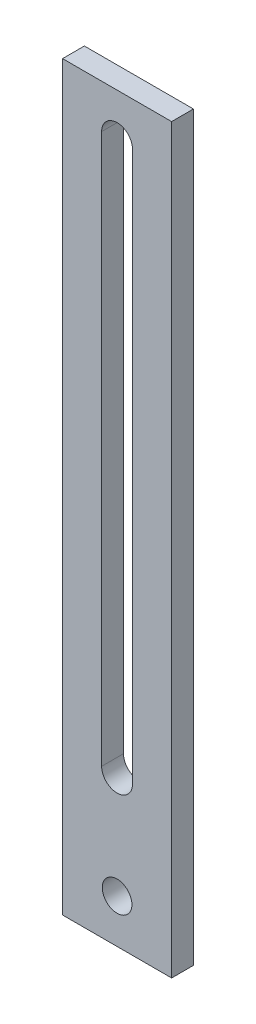
from build123d import *

# Parameters (mm, degrees)
SKETCH1_W           = 15.875
SKETCH1_H           = 107.95
SKETCH1_R           = 2.159
BOSS_EXTRUDE1_DEPTH = 3.175


with BuildPart() as part:
    # Sketch1 → Boss-Extrude1 (new body)
    with BuildSketch(Plane.XY):
        with Locations((7.9375, 53.975)):
            Rectangle(SKETCH1_W, SKETCH1_H)
        with Locations((7.9375, 6.35)):
            Circle(SKETCH1_R, mode=Mode.SUBTRACT)
        with BuildLine():
            Line((10.1854, 101.6), (10.1854, 21.59))
            ThreePointArc((10.1854, 21.59), (7.9375, 19.3421), (5.6896, 21.59))
            Line((5.6896, 21.59), (5.6896, 101.6))
            ThreePointArc((5.6896, 101.6), (7.9375, 103.8479), (10.1854, 101.6))
        make_face(mode=Mode.SUBTRACT)
    extrude(amount=BOSS_EXTRUDE1_DEPTH)


solid = part.part
